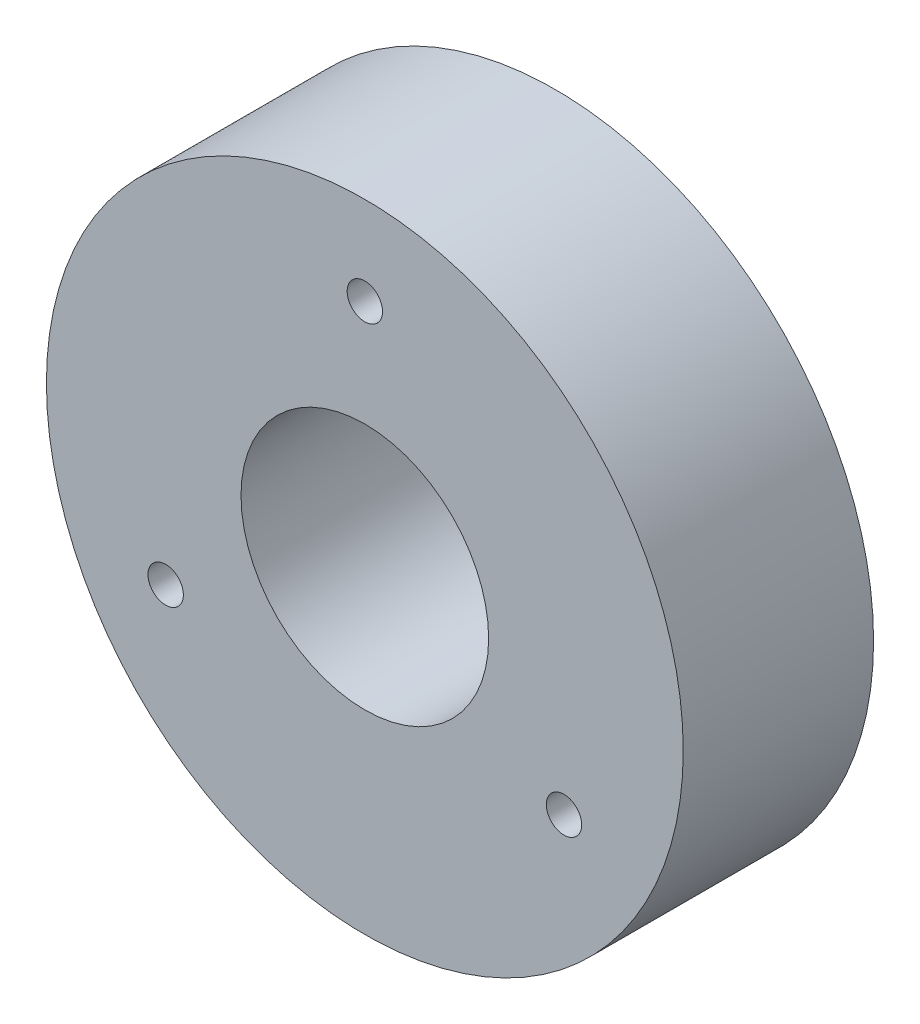
from build123d import *

# Parameters (mm, degrees)
SKETCH1_R           = 45
SKETCH1_R_2         = 2.5
SKETCH1_R_3         = 17.5
BOSS_EXTRUDE1_DEPTH = 26.9
SKETCH1_3_R         = 5
BOSS_EXTRUDE2_DEPTH = 26.9
BOSS_EXTRUDE3_START = -3.2
SKETCH1_4_R         = 17.5
SKETCH1_4_R_2       = 5
BOSS_EXTRUDE3_DEPTH = 3.2


with BuildPart() as part:
    # Sketch1 → Boss-Extrude1 (new body)
    with BuildSketch(Plane.XY):
        Circle(SKETCH1_R)
        with Locations((-28.145825623, -16.25)):
            Circle(SKETCH1_R_2, mode=Mode.SUBTRACT)
        with Locations((28.145825623, -16.25)):
            Circle(SKETCH1_R_2, mode=Mode.SUBTRACT)
        Circle(SKETCH1_R_3, mode=Mode.SUBTRACT)
        with Locations((0, 32.5)):
            Circle(SKETCH1_R_2, mode=Mode.SUBTRACT)
    extrude(amount=BOSS_EXTRUDE1_DEPTH)


with BuildPart() as body_2:
    # Sketch1_3 → Boss-Extrude2 (new body)
    with BuildSketch(Plane.XY):
        Circle(SKETCH1_3_R)
    extrude(amount=-BOSS_EXTRUDE2_DEPTH)

    # Sketch1_4 → Boss-Extrude3 (add)
    with BuildSketch(Plane.XY.offset(BOSS_EXTRUDE3_START)):
        Circle(SKETCH1_4_R)
        Circle(SKETCH1_4_R_2, mode=Mode.SUBTRACT)
    extrude(amount=BOSS_EXTRUDE3_DEPTH)


solid = Compound([part.part, body_2.part])
